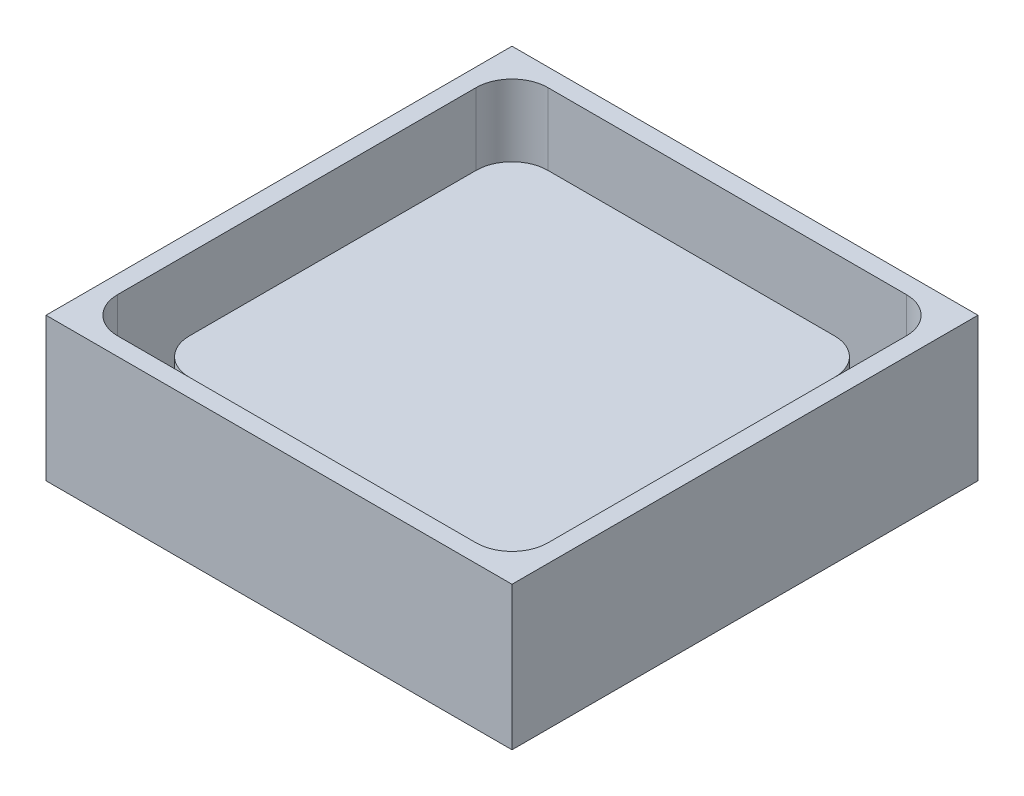
from build123d import *

# Parameters (mm, degrees)
SKETCH1_W           = 20
SKETCH1_H           = 20
BOSS_EXTRUDE1_DEPTH = 6
SKETCH2_W           = 24
SKETCH2_H           = 24
BOSS_EXTRUDE2_DEPTH = 1
SKETCH2_3_W         = 26
SKETCH2_3_H         = 26
SKETCH2_3_W_2       = 24
SKETCH2_3_H_2       = 24
BOSS_EXTRUDE3_DEPTH = 8
FILLET1_R           = 2
FILLET2_R           = 2


with BuildPart() as part:
    # Sketch1 → Boss-Extrude1 (new body)
    with BuildSketch(Plane(origin=(0, 0, 0), x_dir=(1, 0, 0), z_dir=(0, 1, 0))):
        Rectangle(SKETCH1_W, SKETCH1_H)
    extrude(amount=BOSS_EXTRUDE1_DEPTH)

    # Sketch2 → Boss-Extrude2 (add)
    with BuildSketch(Plane(origin=(0, 0, 0), x_dir=(1, 0, 0), z_dir=(0, 1, 0))):
        Rectangle(SKETCH2_W, SKETCH2_H)
    extrude(amount=BOSS_EXTRUDE2_DEPTH)

    # Sketch2_3 → Boss-Extrude3 (add)
    with BuildSketch(Plane(origin=(0, 0, 0), x_dir=(1, 0, 0), z_dir=(0, 1, 0))):
        Rectangle(SKETCH2_3_W, SKETCH2_3_H)
        Rectangle(SKETCH2_3_W_2, SKETCH2_3_H_2, mode=Mode.SUBTRACT)
    extrude(amount=BOSS_EXTRUDE3_DEPTH)

    # Fillet1
    fillet1_edges = [part.edges().sort_by_distance(p)[0] for p in [
        (-10, 3.5, 10),
        (10, 3.5, 10),
        (10, 3.5, -10),
        (-10, 3.5, -10),
    ]]
    fillet(fillet1_edges, radius=FILLET1_R)

    # Fillet2
    fillet2_edges = [part.edges().sort_by_distance(p)[0] for p in [
        (12, 4.5, 12),
        (-12, 4.5, 12),
        (12, 4.5, -12),
        (-12, 4.5, -12),
    ]]
    fillet(fillet2_edges, radius=FILLET2_R)


solid = part.part
